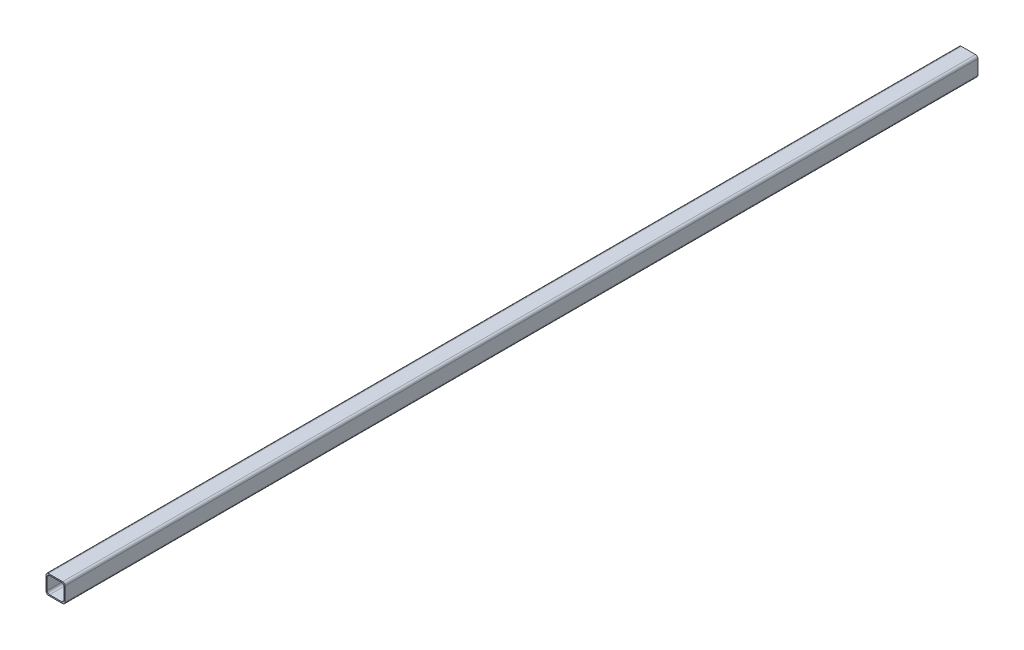
from build123d import *

# Parameters (mm, degrees)
SKETCH1_W           = 25.4
SKETCH1_H           = 25.4
SKETCH1_W_2         = 22.2504
SKETCH1_H_2         = 22.2504
BOSS_EXTRUDE1_DEPTH = 609.6
FILLET1_R           = 3.175


with BuildPart() as part:
    # Sketch1 → Boss-Extrude1 (new body, symmetric)
    with BuildSketch(Plane.XY):
        Rectangle(SKETCH1_W, SKETCH1_H)
        Rectangle(SKETCH1_W_2, SKETCH1_H_2, mode=Mode.SUBTRACT)
    extrude(amount=BOSS_EXTRUDE1_DEPTH, both=True)

    # Fillet1
    fillet1_edges = [part.edges().sort_by_distance(p)[0] for p in [
        (11.1252, -11.1252, 0),
        (11.1252, 11.1252, 0),
        (-11.1252, 11.1252, 0),
        (-11.1252, -11.1252, 0),
        (12.7, -12.7, 0),
        (-12.7, -12.7, 0),
        (-12.7, 12.7, 0),
        (12.7, 12.7, 0),
    ]]
    fillet(fillet1_edges, radius=FILLET1_R)


solid = part.part
